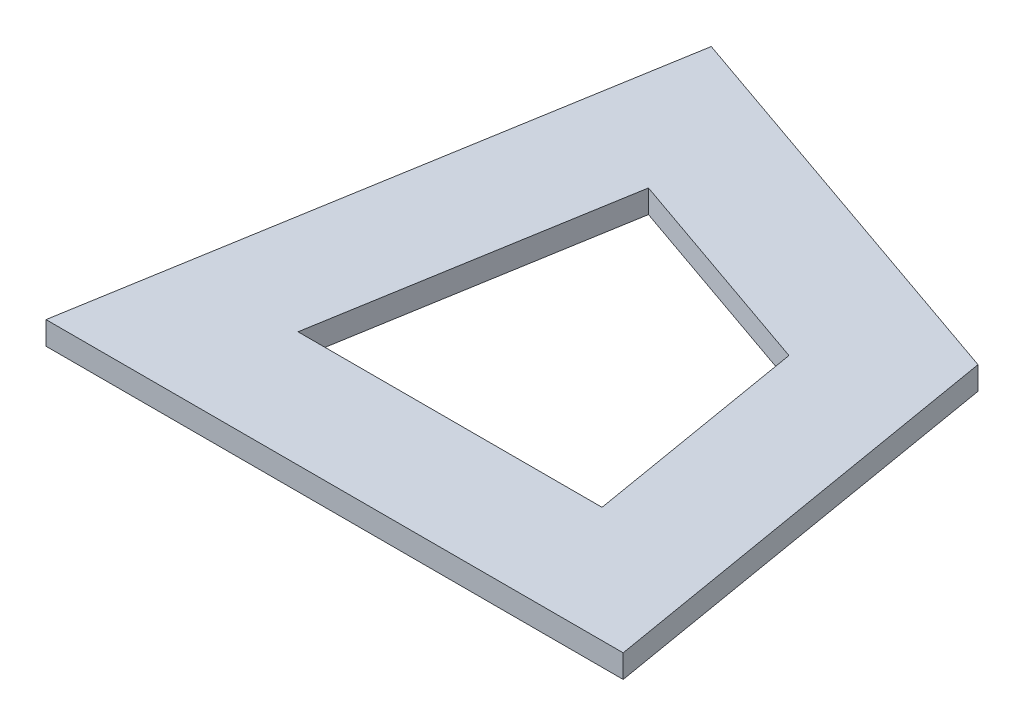
from build123d import *

# Parameters (mm, degrees)
BOSS_EXTRUDE1_DEPTH = 2


with BuildPart() as part:
    # Sketch1 → Boss-Extrude1 (new body)
    with BuildSketch(Plane(origin=(0, 0, 0), x_dir=(1, 0, 0), z_dir=(0, 1, 0))):
        Polygon((0, 0), (50, 0), (43.750605737, 36.987896111), (8.32983277, 49.301256434), align=None)
        Polygon((16.219410185, 35.971586584), (11.831307555, 10), (38.168692445, 10), (34.876408287, 29.485834836), align=None, mode=Mode.SUBTRACT)
    extrude(amount=BOSS_EXTRUDE1_DEPTH)


solid = part.part
